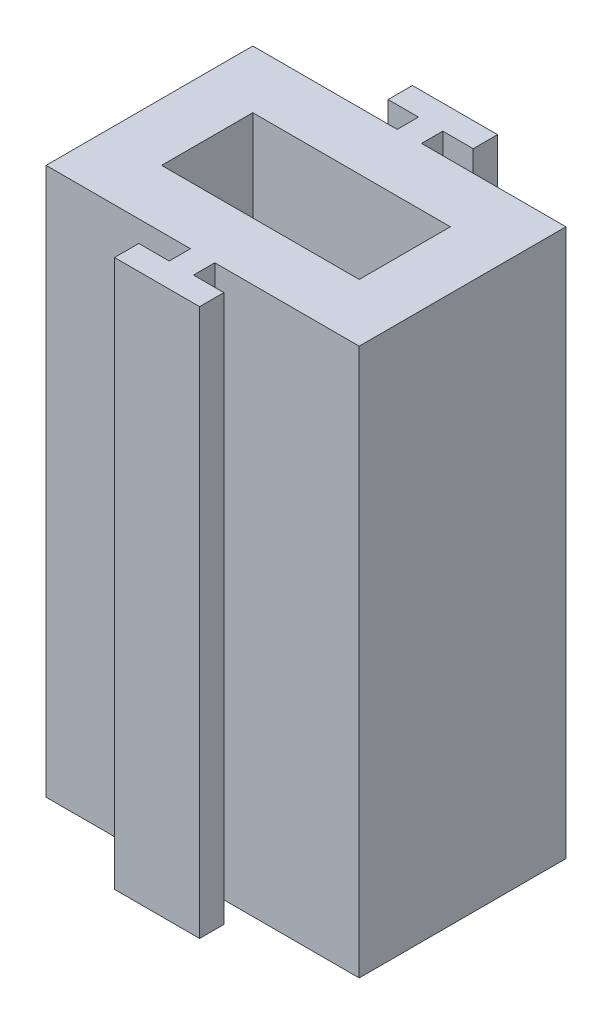
from build123d import *

# Parameters (mm, degrees)
SKETCH3_W           = 2.8
SKETCH3_H           = 0.8
SKETCH3_W_2         = 0.8
SKETCH3_H_2         = 0.1
SKETCH3_H_3         = 0.4
SKETCH3_H_4         = 6.8
SKETCH3_W_3         = 0.1
SKETCH3_W_4         = 4.65
BOSS_EXTRUDE7_DEPTH = 18
SKETCH24_W          = 6.5
SKETCH24_H          = 3
CUT_EXTRUDE25_DEPTH = 18


with BuildPart() as part:
    # Sketch3 → Boss-Extrude7 (new body)
    with BuildSketch(Plane(origin=(0, 0, 0), x_dir=(1, 0, 0), z_dir=(0, 1, 0))):
        with Locations((0, 4.5)):
            Rectangle(SKETCH3_W, SKETCH3_H)
        with Locations((0, 4.05)):
            Rectangle(SKETCH3_W_2, SKETCH3_H_2)
        with Locations((0, 3.95)):
            Rectangle(SKETCH3_W_2, SKETCH3_H_2)
        with Locations((0, 3.7)):
            Rectangle(SKETCH3_W_2, SKETCH3_H_3)
        with Locations((0, 3.45)):
            Rectangle(SKETCH3_W_2, SKETCH3_H_2)
        Rectangle(SKETCH3_W_2, SKETCH3_H_4)
        with Locations((0.45, 0)):
            Rectangle(SKETCH3_W_3, SKETCH3_H_4)
        with Locations((2.825, 0)):
            Rectangle(SKETCH3_W_4, SKETCH3_H_4)
        with Locations((-0.45, 0)):
            Rectangle(SKETCH3_W_3, SKETCH3_H_4)
        with Locations((-2.825, 0)):
            Rectangle(SKETCH3_W_4, SKETCH3_H_4)
        with Locations((0, -3.45)):
            Rectangle(SKETCH3_W_2, SKETCH3_H_2)
        with Locations((0, -3.7)):
            Rectangle(SKETCH3_W_2, SKETCH3_H_3)
        with Locations((0, -3.95)):
            Rectangle(SKETCH3_W_2, SKETCH3_H_2)
        with Locations((0, -4.05)):
            Rectangle(SKETCH3_W_2, SKETCH3_H_2)
        with Locations((0, -4.5)):
            Rectangle(SKETCH3_W, SKETCH3_H)
    extrude(amount=BOSS_EXTRUDE7_DEPTH)

    # Sketch24 → Cut-Extrude25 (cut)
    with BuildSketch(Plane(origin=(0, 18, 0), x_dir=(1, 0, 0), z_dir=(0, 1, 0))):
        Rectangle(SKETCH24_W, SKETCH24_H)
    extrude(amount=-CUT_EXTRUDE25_DEPTH, mode=Mode.SUBTRACT)


solid = part.part
